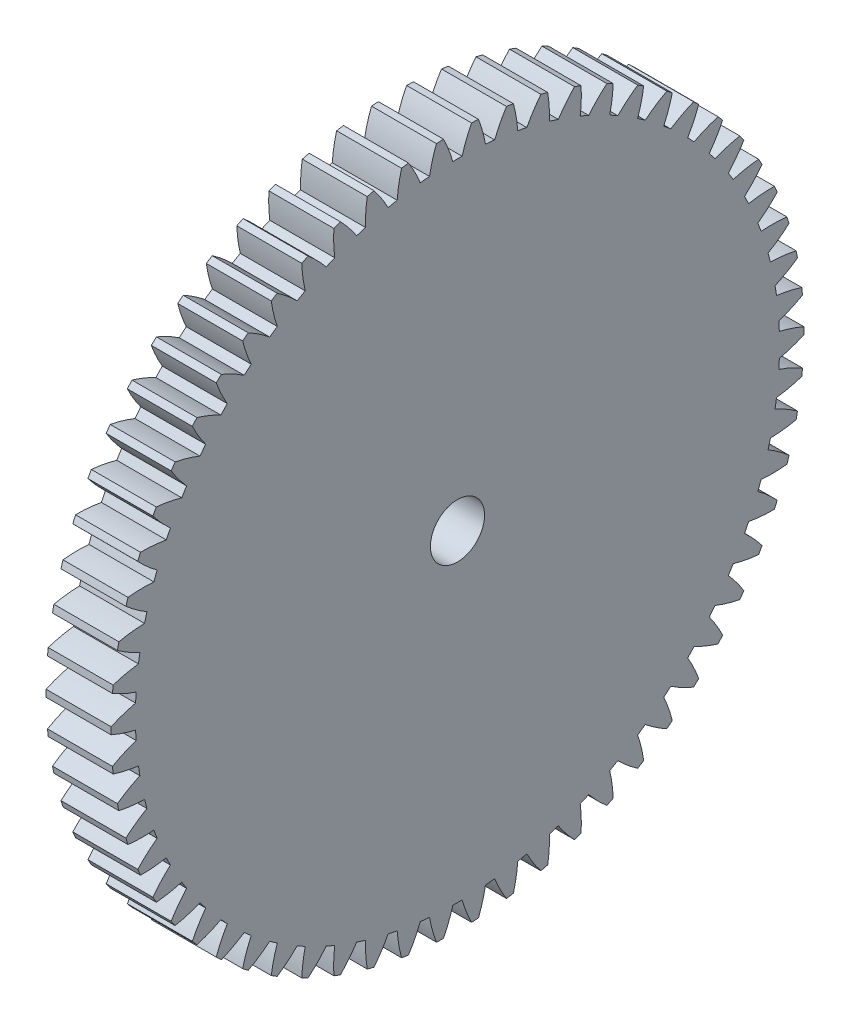
from build123d import *

# Parameters (mm, degrees)
BASPROSKE_W        = 3
BASPROSKE_H        = 16
TOOTHCUT_DEPTH     = 23.825424421
TEETHCUTS_COUNT    = 62
TEETHCUTS_ANGLE    = 354.193548387
BORSKE_R           = 0.75
BORE_DEPTH         = 50.0000508
SKETCH1_R          = 1.25
CUT_EXTRUDE1_DEPTH = 10


with BuildPart() as part:
    # BasProSke → Base-Revolve (revolve)
    with BuildSketch(Plane(origin=(0, 0, 0), x_dir=(1, 0, 0), z_dir=(0, 1, 0)), mode=Mode.PRIVATE) as base_revolve_sk:
        with Locations((1.5, 8)):
            Rectangle(BASPROSKE_W, BASPROSKE_H)
    revolve(base_revolve_sk.sketch.rotate(Axis((-10, 0, 0), (1, 0, 0)), 180), axis=Axis((-10, 0, 0), (1, 0, 0)))

    # TooCutSke → ToothCut (cut, through all)
    with BuildSketch(Plane(origin=(0, 0, 0), x_dir=(0, 0, -1), z_dir=(1, 0, 0))):
        with BuildLine():
            ThreePointArc((0.214322899, 14.872455806), (0, 14.874), (-0.214322899, 14.872455806))
            ThreePointArc((-0.214322899, 14.872455806), (-0.409654178, 15.45315883), (-0.661345859, 16.011747775))
            ThreePointArc((-0.661345859, 16.011747775), (0, 16.0254), (0.661345859, 16.011747775))
            ThreePointArc((0.661345859, 16.011747775), (0.409654178, 15.45315883), (0.214322899, 14.872455806))
        make_face()
    toothcut = extrude(amount=TOOTHCUT_DEPTH, mode=Mode.SUBTRACT)

    # TeethCuts: ToothCut ×62 about axis
    teethcuts_axis = Axis((-10, 0, 0), (1, 0, 0))
    for i in range(1, TEETHCUTS_COUNT):
        add(toothcut.rotate(teethcuts_axis, i * TEETHCUTS_ANGLE / (TEETHCUTS_COUNT - 1)), mode=Mode.SUBTRACT)

    # BorSke → Bore (cut, symmetric)
    with BuildSketch(Plane(origin=(0, 0, 0), x_dir=(0, 0, -1), z_dir=(1, 0, 0))):
        with Locations(Location((0, 0, 0), (0, 0, 180))):
            Circle(BORSKE_R)
    extrude(amount=BORE_DEPTH, both=True, mode=Mode.SUBTRACT)

    # Sketch1 → Cut-Extrude1 (cut)
    with BuildSketch(Plane(origin=(3, 0, 0), x_dir=(0, 0, -1), z_dir=(1, 0, 0))):
        Circle(SKETCH1_R)
    extrude(amount=-CUT_EXTRUDE1_DEPTH, mode=Mode.SUBTRACT)


solid = part.part
